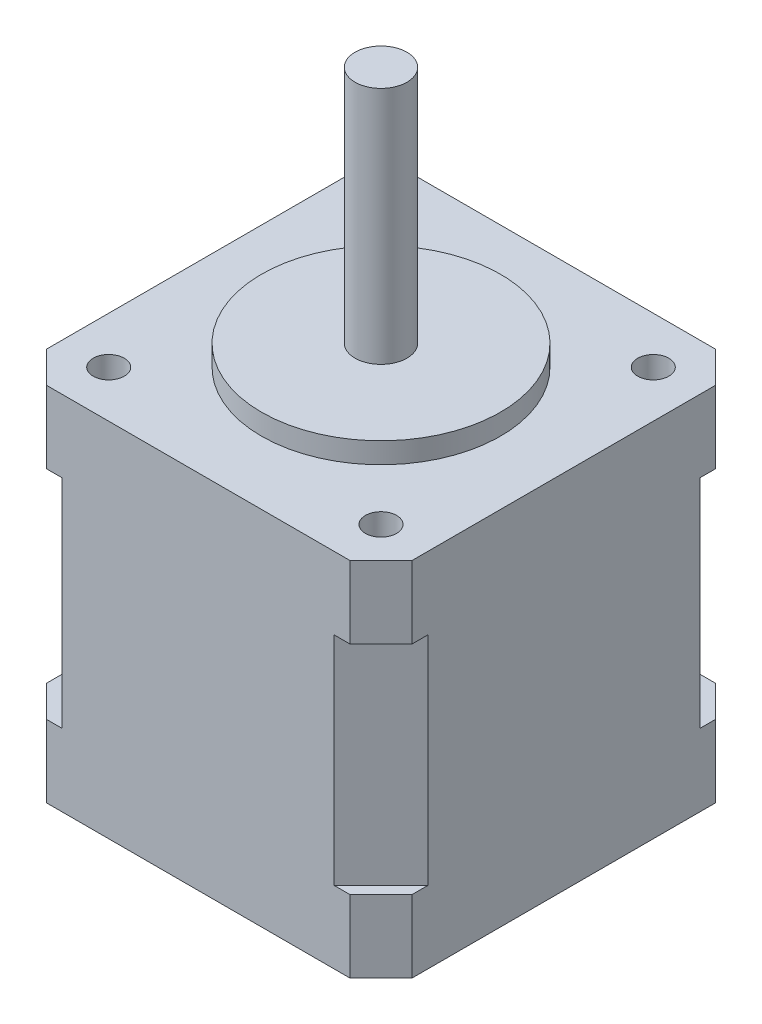
from build123d import *

# Parameters (mm, degrees)
SKETCH1_W               = 35.2
SKETCH1_H               = 35.2
BOSS_EXTRUDE1_DEPTH     = 34.8
SKETCH2_R               = 11.5
BOSS_EXTRUDE2_DEPTH     = 2
SKETCH3_R               = 2.5
BOSS_EXTRUDE3_DEPTH     = 23
SKETCH4_R               = 1.5
CUT_EXTRUDE1_DEPTH      = 8
MIRROR2_COPY_1_SKETCH_R = 1.5
MIRROR2_COPY_1_DEPTH    = 8
CUT_EXTRUDE2_DEPTH      = 6.96
MIRROR4_COPY_1_DEPTH    = 6.96
CUT_EXTRUDE3_DEPTH      = 6.96
MIRROR6_COPY_1_DEPTH    = 6.96
SKETCH7_R               = 2.5
CUT_EXTRUDE4_DEPTH      = 5
CUT_EXTRUDE6_DEPTH      = 20.88
CUT_EXTRUDE7_DEPTH      = 20.88
CUT_EXTRUDE8_DEPTH      = 20.88
CUT_EXTRUDE9_DEPTH      = 20.88


with BuildPart() as part:
    # Sketch1 → Boss-Extrude1 (new body)
    with BuildSketch(Plane(origin=(0, 0, 0), x_dir=(1, 0, 0), z_dir=(0, 1, 0))):
        Rectangle(SKETCH1_W, SKETCH1_H)
    extrude(amount=BOSS_EXTRUDE1_DEPTH)

    # Sketch2 → Boss-Extrude2 (add)
    with BuildSketch(Plane(origin=(0, 34.8, 0), x_dir=(1, 0, 0), z_dir=(0, 1, 0))):
        Circle(SKETCH2_R)
    extrude(amount=BOSS_EXTRUDE2_DEPTH)

    # Sketch3 → Boss-Extrude3 (add)
    with BuildSketch(Plane(origin=(0, 36.8, 0), x_dir=(1, 0, 0), z_dir=(0, 1, 0))):
        Circle(SKETCH3_R)
    extrude(amount=BOSS_EXTRUDE3_DEPTH)

    # Sketch4 → Cut-Extrude1 (cut)
    with BuildSketch(Plane(origin=(0, 34.8, 0), x_dir=(1, 0, 0), z_dir=(0, 1, 0))):
        with Locations((-13.1, 13.1)):
            Circle(SKETCH4_R)
    cut_extrude1 = extrude(amount=-CUT_EXTRUDE1_DEPTH, mode=Mode.SUBTRACT)

    # Mirror1: Cut-Extrude1 across plane
    add(cut_extrude1.mirror(Plane(origin=(0, 0, 0), x_dir=(0, 0, 1), z_dir=(1, 0, 0))), mode=Mode.SUBTRACT)

    # Mirror2: Cut-Extrude1 across plane
    add(cut_extrude1.mirror(Plane.XY), mode=Mode.SUBTRACT)

    # Mirror2 copy 1 sketch → Mirror2 copy 1 (cut)
    with BuildSketch(Plane(origin=(0, 34.8, 0), x_dir=(-1, 0, 0), z_dir=(0, 1, 0))):
        with Locations((-13.1, 13.1)):
            Circle(MIRROR2_COPY_1_SKETCH_R)
    extrude(amount=-MIRROR2_COPY_1_DEPTH, mode=Mode.SUBTRACT)

    # Sketch5 → Cut-Extrude2 (cut)
    with BuildSketch(Plane(origin=(0, 34.8, 0), x_dir=(1, 0, 0), z_dir=(0, 1, 0))):
        Polygon((-17.6, 17.6), (-14.6, 17.6), (-17.6, 14.6), align=None)
    cut_extrude2 = extrude(amount=-CUT_EXTRUDE2_DEPTH, mode=Mode.SUBTRACT)

    # Mirror3: Cut-Extrude2 across plane
    add(cut_extrude2.mirror(Plane(origin=(0, 0, 0), x_dir=(0, 0, 1), z_dir=(1, 0, 0))), mode=Mode.SUBTRACT)

    # Mirror4: Cut-Extrude2 across plane
    add(cut_extrude2.mirror(Plane.XY), mode=Mode.SUBTRACT)

    # Mirror4 copy 1 sketch → Mirror4 copy 1 (cut)
    with BuildSketch(Plane(origin=(0, 34.8, 0), x_dir=(-1, 0, 0), z_dir=(0, 1, 0))):
        Polygon((-17.6, 17.6), (-14.6, 17.6), (-17.6, 14.6), align=None)
    extrude(amount=-MIRROR4_COPY_1_DEPTH, mode=Mode.SUBTRACT)

    # Sketch6 → Cut-Extrude3 (cut)
    with BuildSketch(Plane.XZ):
        Polygon((-17.6, 17.6), (-14.6, 17.6), (-17.6, 14.6), align=None)
    cut_extrude3 = extrude(amount=-CUT_EXTRUDE3_DEPTH, mode=Mode.SUBTRACT)

    # Mirror5: Cut-Extrude3 across plane
    add(cut_extrude3.mirror(Plane(origin=(0, 0, 0), x_dir=(0, 0, 1), z_dir=(1, 0, 0))), mode=Mode.SUBTRACT)

    # Mirror6: Cut-Extrude3 across plane
    add(cut_extrude3.mirror(Plane.XY), mode=Mode.SUBTRACT)

    # Mirror6 copy 1 sketch → Mirror6 copy 1 (cut)
    with BuildSketch(Plane(origin=(0, 0, 0), x_dir=(-1, 0, 0), z_dir=(0, -1, 0))):
        Polygon((-17.6, 17.6), (-14.6, 17.6), (-17.6, 14.6), align=None)
    extrude(amount=-MIRROR6_COPY_1_DEPTH, mode=Mode.SUBTRACT)

    # Sketch7 → Cut-Extrude4 (cut)
    with BuildSketch(Plane.XZ):
        Circle(SKETCH7_R)
    extrude(amount=-CUT_EXTRUDE4_DEPTH, mode=Mode.SUBTRACT)

    # Sketch8 → Cut-Extrude6 (cut)
    with BuildSketch(Plane(origin=(0, 27.84, 0), x_dir=(1, 0, 0), z_dir=(0, 1, 0))):
        Polygon((-17.6, 17.6), (-13.1, 17.6), (-17.6, 13.1), align=None)
    extrude(amount=-CUT_EXTRUDE6_DEPTH, mode=Mode.SUBTRACT)

    # Sketch9 → Cut-Extrude7 (cut)
    with BuildSketch(Plane(origin=(0, 27.84, 0), x_dir=(1, 0, 0), z_dir=(0, 1, 0))):
        Polygon((17.6, 17.6), (13.1, 17.6), (17.6, 13.1), align=None)
    extrude(amount=-CUT_EXTRUDE7_DEPTH, mode=Mode.SUBTRACT)

    # Sketch10 → Cut-Extrude8 (cut)
    with BuildSketch(Plane(origin=(0, 27.84, 0), x_dir=(1, 0, 0), z_dir=(0, 1, 0))):
        Polygon((17.6, -17.6), (17.6, -13.1), (13.1, -17.6), align=None)
    extrude(amount=-CUT_EXTRUDE8_DEPTH, mode=Mode.SUBTRACT)

    # Sketch11 → Cut-Extrude9 (cut)
    with BuildSketch(Plane(origin=(0, 27.84, 0), x_dir=(1, 0, 0), z_dir=(0, 1, 0))):
        Polygon((-17.6, -17.6), (-17.6, -13.1), (-13.1, -17.6), align=None)
    extrude(amount=-CUT_EXTRUDE9_DEPTH, mode=Mode.SUBTRACT)


solid = part.part
